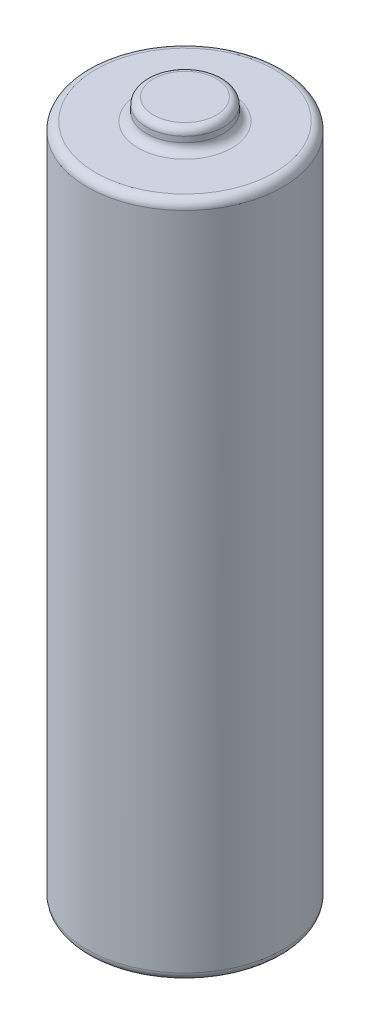
from build123d import *

# Parameters (mm, degrees)
SKETCH1_R           = 7
BOSS_EXTRUDE1_DEPTH = 49
SKETCH2_R           = 2.75
BOSS_EXTRUDE2_DEPTH = 1.5
FILLET2_R           = 0.6
FILLET3_R           = 0.5
SKETCH4_R           = 7
SKETCH4_R_2         = 4.6
CUT_EXTRUDE2_DEPTH  = 0.5
FILLET7_R           = 0.6
FILLET8_R           = 0.6
FILLET9_R           = 0.1
FILLET10_R          = 0.5


with BuildPart() as part:
    # Sketch1 → Boss-Extrude1 (new body)
    with BuildSketch(Plane(origin=(0, 0, 0), x_dir=(1, 0, 0), z_dir=(0, 1, 0))):
        Circle(SKETCH1_R)
    extrude(amount=BOSS_EXTRUDE1_DEPTH)

    # Sketch2 → Boss-Extrude2 (add)
    with BuildSketch(Plane(origin=(0, 49, 0), x_dir=(1, 0, 0), z_dir=(0, 1, 0))):
        Circle(SKETCH2_R)
    extrude(amount=BOSS_EXTRUDE2_DEPTH)

    # Fillet2
    fillet2_edges = [part.edges().sort_by_distance(p)[0] for p in [
        (-2.75, 49, 0),
    ]]
    fillet(fillet2_edges, radius=FILLET2_R)

    # Fillet3
    fillet3_edges = [part.edges().sort_by_distance(p)[0] for p in [
        (-2.75, 50.5, 0),
    ]]
    fillet(fillet3_edges, radius=FILLET3_R)

    # Sketch4 → Cut-Extrude2 (cut)
    with BuildSketch(Plane.XZ):
        Circle(SKETCH4_R)
        Circle(SKETCH4_R_2, mode=Mode.SUBTRACT)
    extrude(amount=-CUT_EXTRUDE2_DEPTH, mode=Mode.SUBTRACT)

    # Fillet7
    fillet7_edges = [part.edges().sort_by_distance(p)[0] for p in [
        (-7, 0.5, 0),
    ]]
    fillet(fillet7_edges, radius=FILLET7_R)

    # Fillet8
    fillet8_edges = [part.edges().sort_by_distance(p)[0] for p in [
        (-7, 49, 0),
    ]]
    fillet(fillet8_edges, radius=FILLET8_R)

    # Fillet9
    fillet9_edges = [part.edges().sort_by_distance(p)[0] for p in [
        (-4.6, 0, 0),
    ]]
    fillet(fillet9_edges, radius=FILLET9_R)

    # Fillet10
    fillet10_edges = [part.edges().sort_by_distance(p)[0] for p in [
        (-4.6, 0.5, 0),
    ]]
    fillet(fillet10_edges, radius=FILLET10_R)


solid = part.part
